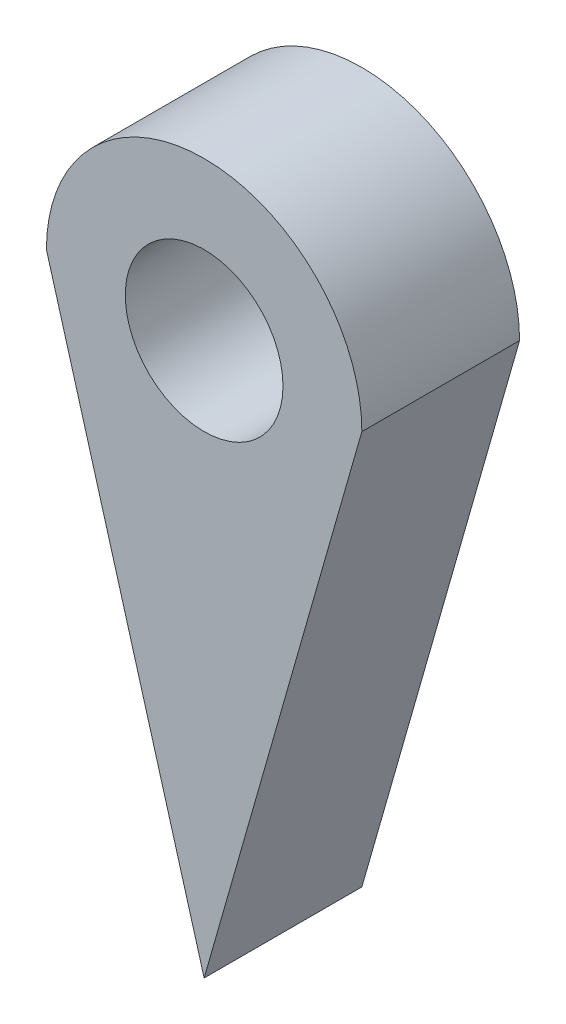
from build123d import *

# Parameters (mm, degrees)
BOSS_EXTRUDE1_DEPTH = 4


with BuildPart() as part:
    # Sketch1 → Boss-Extrude1 (new body)
    with BuildSketch(Plane.XY):
        with BuildLine():
            ThreePointArc((3.396226415, -2.113207547), (0, -4), (-3.396226415, -2.113207547))
            Line((-3.396226415, -2.113207547), (0, -14))
            Line((0, -14), (3.396226415, -2.113207547))
        make_face()
        with BuildLine():
            Line((-2, 0), (-4, 0))
            Line((-4, 0), (-3.396226415, -2.113207547))
            ThreePointArc((-3.396226415, -2.113207547), (0, -4), (3.396226415, -2.113207547))
            Line((3.396226415, -2.113207547), (4, 0))
            Line((4, 0), (2, 0))
            ThreePointArc((2, 0), (0, -2), (-2, 0))
        make_face()
        with BuildLine():
            ThreePointArc((4, 0), (0, 4), (-4, 0))
            Line((-4, 0), (-2, 0))
            ThreePointArc((-2, 0), (0, 2), (2, 0))
            Line((2, 0), (4, 0))
        make_face()
    extrude(amount=BOSS_EXTRUDE1_DEPTH)


solid = part.part
